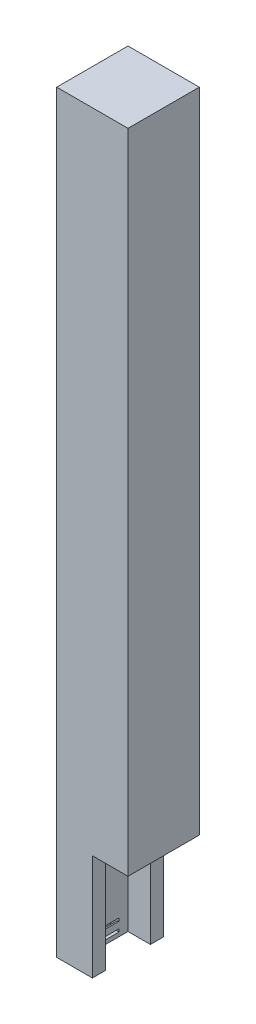
from build123d import *

# Parameters (mm, degrees)
SKETCH2_W           = 22.225
SKETCH2_H           = 22.225
SKETCH2_W_2         = 13.97
SKETCH2_H_2         = 13.97
BOSS_EXTRUDE1_DEPTH = 6.35
SKETCH3_W           = 8.382
SKETCH3_H           = 3.81
CUT_EXTRUDE1_DEPTH  = 2.54
BOSS_EXTRUDE2_DEPTH = 8.382
SKETCH6_W           = 22.225
SKETCH6_H           = 22.225
SKETCH6_W_2         = 13.97
SKETCH6_H_2         = 13.97
BOSS_EXTRUDE3_DEPTH = 222.25
SKETCH7_W           = 22.225
SKETCH7_H           = 22.225
BOSS_EXTRUDE4_DEPTH = 6.35
SKETCH8_W           = 11.1125
SKETCH8_H           = 22.225
CUT_EXTRUDE2_DEPTH  = 33.02


with BuildPart() as part:
    # Sketch2 → Boss-Extrude1 (new body)
    with BuildSketch(Plane(origin=(0, 0, 0), x_dir=(1, 0, 0), z_dir=(0, 1, 0))):
        Rectangle(SKETCH2_W, SKETCH2_H)
        Rectangle(SKETCH2_W_2, SKETCH2_H_2, mode=Mode.SUBTRACT)
    extrude(amount=BOSS_EXTRUDE1_DEPTH)

    # Sketch3 → Cut-Extrude1 (cut)
    with BuildSketch(Plane(origin=(-6.985, 0, 0), x_dir=(0, 0, -1), z_dir=(1, 0, 0))):
        with Locations((0, 3.175)):
            Rectangle(SKETCH3_W, SKETCH3_H)
    extrude(amount=-CUT_EXTRUDE1_DEPTH, mode=Mode.SUBTRACT)

    # Sketch4 → Boss-Extrude2 (add)
    with BuildSketch(Plane(origin=(0, 0, 4.191), x_dir=(-1, 0, 0), z_dir=(0, 0, -1))):
        with BuildLine():
            Line((6.985, 4.191), (6.985, 2.159))
            ThreePointArc((6.985, 2.159), (8.001, 3.175), (6.985, 4.191))
        make_face()
    extrude(amount=BOSS_EXTRUDE2_DEPTH)

    # Sketch6 → Boss-Extrude3 (add)
    with BuildSketch(Plane(origin=(0, 6.35, 0), x_dir=(1, 0, 0), z_dir=(0, 1, 0))):
        Rectangle(SKETCH6_W, SKETCH6_H)
        Rectangle(SKETCH6_W_2, SKETCH6_H_2, mode=Mode.SUBTRACT)
    extrude(amount=BOSS_EXTRUDE3_DEPTH)

    # Sketch7 → Boss-Extrude4 (add)
    with BuildSketch(Plane(origin=(0, 228.6, 0), x_dir=(1, 0, 0), z_dir=(0, 1, 0))):
        Rectangle(SKETCH7_W, SKETCH7_H)
    extrude(amount=BOSS_EXTRUDE4_DEPTH)

    # Sketch8 → Cut-Extrude2 (cut)
    with BuildSketch(Plane.XZ):
        with Locations((5.55625, 0)):
            Rectangle(SKETCH8_W, SKETCH8_H)
    extrude(amount=-CUT_EXTRUDE2_DEPTH, mode=Mode.SUBTRACT)


solid = part.part
